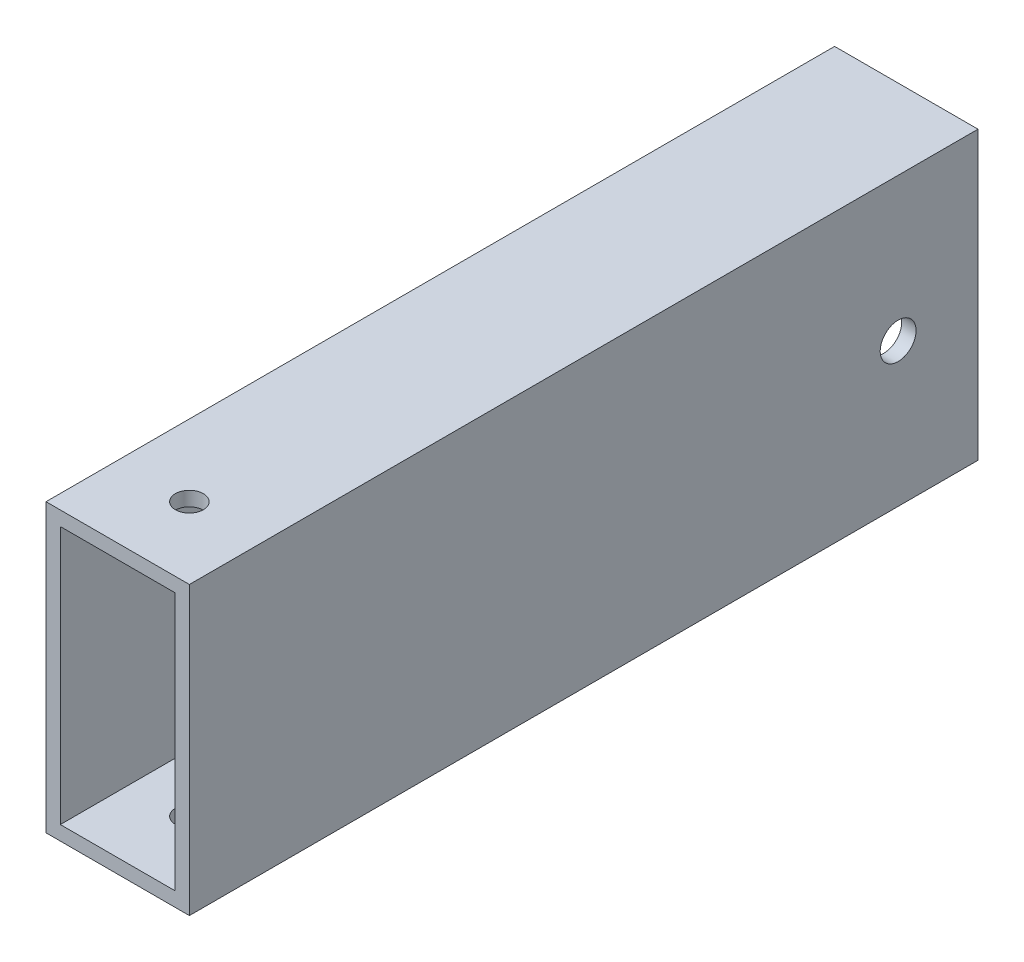
from build123d import *

# Parameters (mm, degrees)
SKETCH1_W           = 25.4
SKETCH1_H           = 50.8
SKETCH1_W_2         = 20.32
SKETCH1_H_2         = 45.72
EXTRUDE_THIN1_DEPTH = 69.85
SKETCH2_R           = 3.175
CUT_EXTRUDE1_DEPTH  = 26.4
SKETCH4_R           = 2.4765
CUT_EXTRUDE3_DEPTH  = 51.8


with BuildPart() as part:
    # Sketch1 → Extrude-Thin1 (new body, symmetric)
    with BuildSketch(Plane.XY):
        Rectangle(SKETCH1_W, SKETCH1_H)
        Rectangle(SKETCH1_W_2, SKETCH1_H_2, mode=Mode.SUBTRACT)
    extrude(amount=EXTRUDE_THIN1_DEPTH, both=True)

    # Sketch2 → Cut-Extrude1 (cut, through all)
    with BuildSketch(Plane(origin=(12.7, 0, 0), x_dir=(0, 0, -1), z_dir=(1, 0, 0))):
        with Locations((55.7022, 0)):
            Circle(SKETCH2_R)
    extrude(amount=-CUT_EXTRUDE1_DEPTH, mode=Mode.SUBTRACT)

    # Sketch4 → Cut-Extrude3 (cut, through all)
    with BuildSketch(Plane(origin=(0, 25.4, 0), x_dir=(1, 0, 0), z_dir=(0, 1, 0))):
        with Locations((0, -57.15)):
            Circle(SKETCH4_R)
    extrude(amount=-CUT_EXTRUDE3_DEPTH, mode=Mode.SUBTRACT)


solid = part.part
